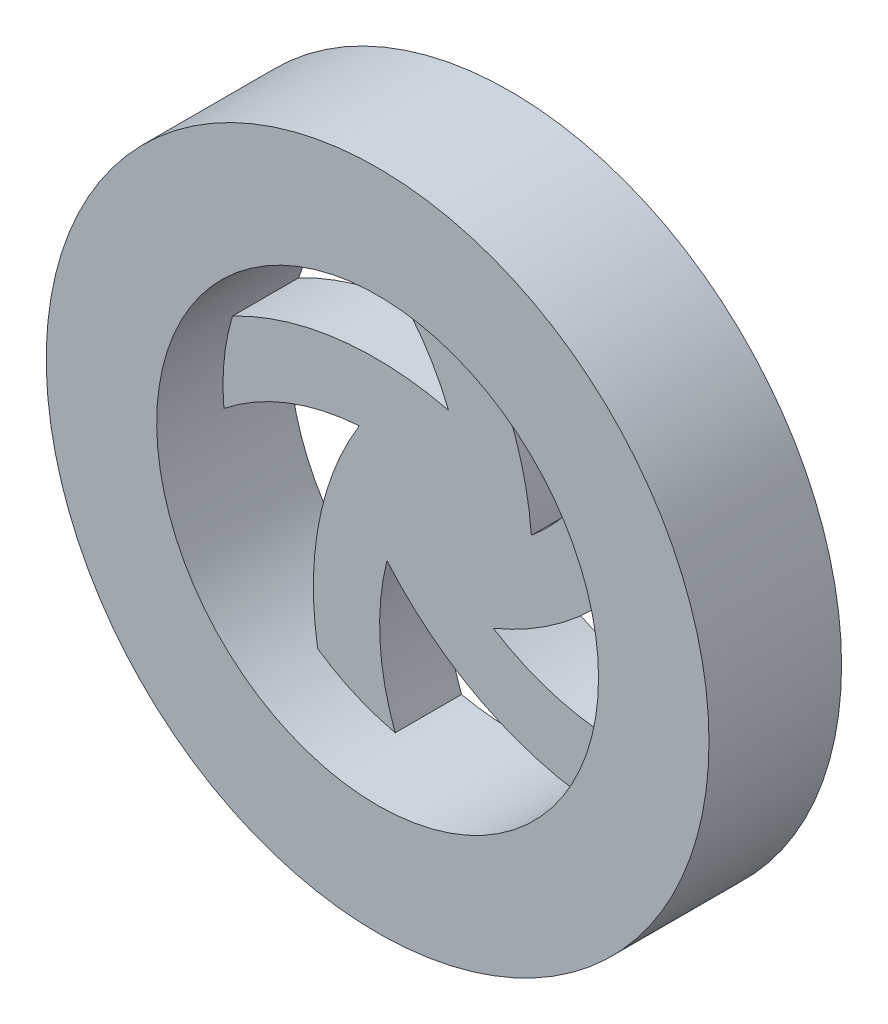
from build123d import *

# Parameters (mm, degrees)
SKETCH1_R           = 75
SKETCH1_R_2         = 50
BOSS_EXTRUDE1_DEPTH = 30
BOSS_EXTRUDE2_DEPTH = 15


with BuildPart() as part:
    # Sketch1 → Boss-Extrude1 (new body)
    with BuildSketch(Plane.XY):
        Circle(SKETCH1_R)
        Circle(SKETCH1_R_2, mode=Mode.SUBTRACT)
    extrude(amount=BOSS_EXTRUDE1_DEPTH)

    # Sketch2 → Boss-Extrude2 (add)
    with BuildSketch(Plane(origin=(0, 0, 0), x_dir=(-1, 0, 0), z_dir=(0, 0, -1))):
        with BuildLine():
            ThreePointArc((-19.796645951, 5.331811511), (-30.803499375, 17.794882511), (-37.582797631, 32.977770122))
            ThreePointArc((-37.582797631, 32.977770122), (-43.211113504, 25.15550973), (-47.234297303, 16.398815759))
            ThreePointArc((-47.234297303, 16.398815759), (-32.262837592, -3.666350702), (-11.18835411, -17.180108765))
            ThreePointArc((-11.18835411, -17.180108765), (-26.44274376, -23.796947698), (-42.97744633, -25.552673186))
            ThreePointArc((-42.97744633, -25.552673186), (-37.277279866, -33.322731067), (-30.192401169, -39.854973487))
            ThreePointArc((-30.192401169, -39.854973487), (-6.482858375, -31.816746601), (12.881862833, -15.949702657))
            ThreePointArc((12.881862833, -15.949702657), (14.460984976, -32.502205015), (11.021275052, -48.770190652))
            ThreePointArc((11.021275052, -48.770190652), (20.17248754, -45.750090125), (28.57436718, -41.030543992))
            ThreePointArc((28.57436718, -41.030543992), (28.256210772, -15.997480106), (19.149783179, 7.322650414))
            ThreePointArc((19.149783179, 7.322650414), (35.380123986, 3.709480291), (49.788968911, -4.588962272))
            ThreePointArc((49.788968911, -4.588962272), (49.947214365, -2.296906009), (50, 0))
            ThreePointArc((50, 0), (49.460168644, 7.327463252), (47.852331292, 14.496702726))
            ThreePointArc((47.852331292, 14.496702726), (23.946157025, 21.929760162), (-1.046645951, 20.4753495))
            ThreePointArc((-1.046645951, 20.4753495), (7.405134174, 34.794789915), (19.75, 45.934055993))
            ThreePointArc((19.75, 45.934055993), (10.571343028, 48.869691083), (1, 49.989999))
            ThreePointArc((1, 49.989999), (-13.45667183, 29.550817252), (-19.796645951, 5.331811511))
        make_face()
    extrude(amount=-BOSS_EXTRUDE2_DEPTH)


solid = part.part
